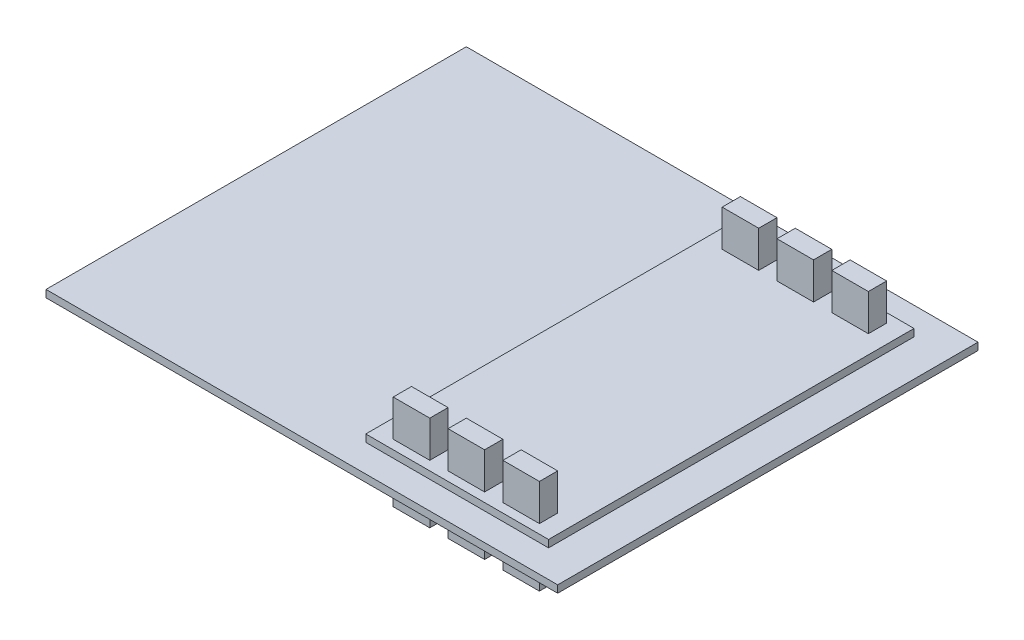
from build123d import *

# Parameters (mm, degrees)
SKETCH1_W                = 177.8
SKETCH1_H                = 146.05
BOSS_EXTRUDE1_DEPTH      = 2.54
SKETCH2_W                = 63.5
SKETCH2_H                = 127
BOSS_EXTRUDE2_DEPTH      = 2.54
BOSS_EXTRUDE2_DEPTH_BACK = 5.08
SKETCH3_W                = 12.7
SKETCH3_H                = 6.35
BOSS_EXTRUDE3_DEPTH      = 12.7
BOSS_EXTRUDE3_DEPTH_BACK = 20.32


with BuildPart() as part:
    # Sketch1 → Boss-Extrude1 (new body)
    with BuildSketch(Plane(origin=(0, 0, 0), x_dir=(1, 0, 0), z_dir=(0, 1, 0))):
        Rectangle(SKETCH1_W, SKETCH1_H)
    extrude(amount=BOSS_EXTRUDE1_DEPTH)

    # Sketch2 → Boss-Extrude2 (add, two sides)
    with BuildSketch(Plane(origin=(0, 2.54, 0), x_dir=(1, 0, 0), z_dir=(0, 1, 0))) as boss_extrude2_sk:
        with Locations((44.45, 0)):
            Rectangle(SKETCH2_W, SKETCH2_H)
    extrude(amount=BOSS_EXTRUDE2_DEPTH)
    extrude(boss_extrude2_sk.sketch, amount=-BOSS_EXTRUDE2_DEPTH_BACK)

    # Sketch3 → Boss-Extrude3 (add, two sides)
    with BuildSketch(Plane(origin=(0, 5.08, 0), x_dir=(1, 0, 0), z_dir=(0, 1, 0))) as boss_extrude3_sk:
        with Locations((25.4, 57.15)):
            Rectangle(SKETCH3_W, SKETCH3_H)
        with Locations((44.45, 57.15)):
            Rectangle(SKETCH3_W, SKETCH3_H)
        with Locations((63.5, 57.15)):
            Rectangle(SKETCH3_W, SKETCH3_H)
        with Locations((63.5, -57.15)):
            Rectangle(SKETCH3_W, SKETCH3_H)
        with Locations((44.45, -57.15)):
            Rectangle(SKETCH3_W, SKETCH3_H)
        with Locations((25.4, -57.15)):
            Rectangle(SKETCH3_W, SKETCH3_H)
    extrude(amount=BOSS_EXTRUDE3_DEPTH)
    extrude(boss_extrude3_sk.sketch, amount=-BOSS_EXTRUDE3_DEPTH_BACK)


solid = part.part
